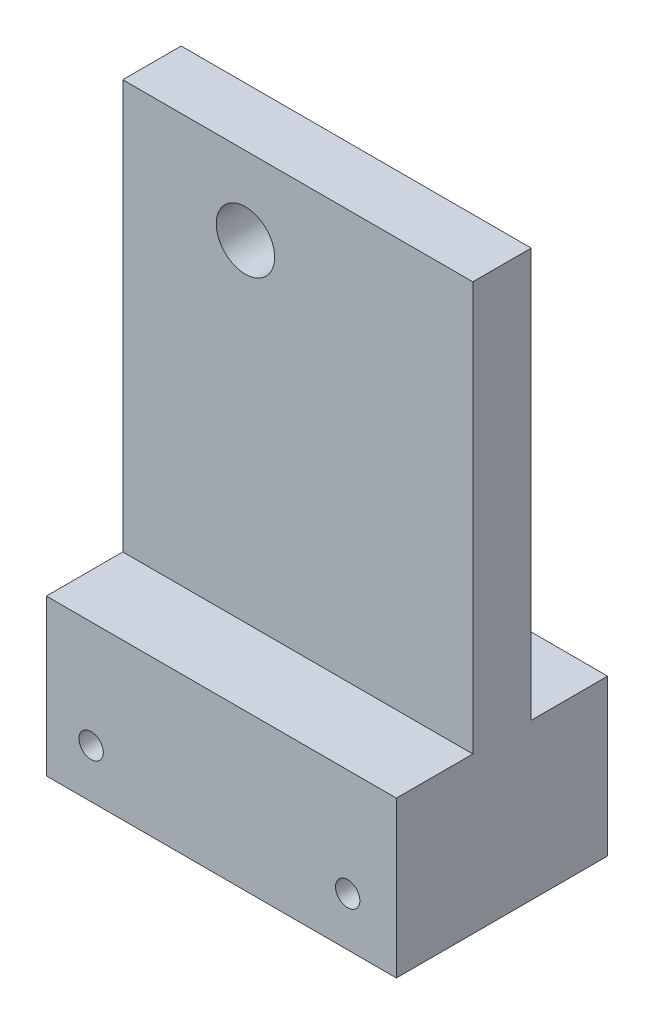
from build123d import *

# Parameters (mm, degrees)
SIDE_W                                      = 35.95
SIDE_H                                      = 10
AUFSATZ_LINEAR_AUSTRAGEN1_DEPTH             = 10.85
AUFSATZ_LINEAR_AUSTRAGEN1_DEPTH_BACK        = 10.85
SKIZZE5_R                                   = 1.25
SCHNITT_LINEAR_AUSTRAGEN1_DEPTH             = 11.85
SCHNITT_LINEAR_AUSTRAGEN1_DEPTH_BACK        = 11.85
TOPEXTENSION_W                              = 35.95
TOPEXTENSION_H                              = 48
TOPEXTENSION_R                              = 3
AUFSATZ_LINEAR_AUSTRAGEN2_DEPTH             = 3
AUFSATZ_LINEAR_AUSTRAGEN2_DEPTH_BACK        = 3
AUFSATZ_LINEAR_AUSTRAGEN3_REACH             = 12.85
SKIZZE8_W                                   = 35.95
SKIZZE8_H                                   = 6
AUFSATZ_LINEAR_AUSTRAGEN3_DIRECTION_2_REACH = 12.85


with BuildPart() as part:
    # Side → Aufsatz-Linear austragen1 (new body, two sides)
    with BuildSketch(Plane.XY) as aufsatz_linear_austragen1_sk:
        with Locations((5.375, 625)):
            Rectangle(SIDE_W, SIDE_H)
    extrude(amount=AUFSATZ_LINEAR_AUSTRAGEN1_DEPTH)
    extrude(aufsatz_linear_austragen1_sk.sketch, amount=-AUFSATZ_LINEAR_AUSTRAGEN1_DEPTH_BACK)

    # Skizze5 → Schnitt-Linear austragen1 (cut, two sides)
    with BuildSketch(Plane.XY) as schnitt_linear_austragen1_sk:
        with Locations((-8, 625)):
            Circle(SKIZZE5_R)
        with Locations((18.35, 625)):
            Circle(SKIZZE5_R)
    extrude(amount=SCHNITT_LINEAR_AUSTRAGEN1_DEPTH, mode=Mode.SUBTRACT)
    extrude(schnitt_linear_austragen1_sk.sketch, amount=-SCHNITT_LINEAR_AUSTRAGEN1_DEPTH_BACK, mode=Mode.SUBTRACT)

    # TopExtension → Aufsatz-Linear austragen2 (add, two sides)
    with BuildSketch(Plane.XY) as aufsatz_linear_austragen2_sk:
        with Locations((5.375, 654)):
            Rectangle(TOPEXTENSION_W, TOPEXTENSION_H)
        with Locations((0, 670)):
            Circle(TOPEXTENSION_R, mode=Mode.SUBTRACT)
    extrude(amount=AUFSATZ_LINEAR_AUSTRAGEN2_DEPTH)
    extrude(aufsatz_linear_austragen2_sk.sketch, amount=-AUFSATZ_LINEAR_AUSTRAGEN2_DEPTH_BACK)

    # Aufsatz-Linear austragen3: up to this face of the body (flat: up to its plane)
    aufsatz_linear_austragen3_end = Plane(part.part.faces().sort_by_distance((5.38061508, 625, 10.85))[0])
    # Skizze8 → Aufsatz-Linear austragen3 (add, up to the picked face)
    with BuildSketch(Plane.XY, mode=Mode.PRIVATE) as aufsatz_linear_austragen3_sk1:
        with Locations((5.375, 633)):
            Rectangle(SKIZZE8_W, SKIZZE8_H)
    aufsatz_linear_austragen3_tool1 = split(extrude(aufsatz_linear_austragen3_sk1.sketch, amount=AUFSATZ_LINEAR_AUSTRAGEN3_REACH, mode=Mode.PRIVATE), bisect_by=aufsatz_linear_austragen3_end, keep=Keep.BOTH, mode=Mode.PRIVATE)
    add(aufsatz_linear_austragen3_tool1.solids().sort_by_distance((5.375, 633, 0))[0])

    # Aufsatz-Linear austragen3 direction 2: up to this face of the body (flat: up to its plane)
    aufsatz_linear_austragen3_direction_2_end = Plane(part.part.faces().sort_by_distance((5.38061508, 625, -10.85))[0])
    # Skizze8 → Aufsatz-Linear austragen3 direction 2 (add, up to the picked face)
    with BuildSketch(Plane.XY, mode=Mode.PRIVATE) as aufsatz_linear_austragen3_direction_2_sk1:
        with Locations((5.375, 633)):
            Rectangle(SKIZZE8_W, SKIZZE8_H)
    aufsatz_linear_austragen3_direction_2_tool1 = split(extrude(aufsatz_linear_austragen3_direction_2_sk1.sketch, amount=-AUFSATZ_LINEAR_AUSTRAGEN3_DIRECTION_2_REACH, mode=Mode.PRIVATE), bisect_by=aufsatz_linear_austragen3_direction_2_end, keep=Keep.BOTH, mode=Mode.PRIVATE)
    add(aufsatz_linear_austragen3_direction_2_tool1.solids().sort_by_distance((5.375, 633, 0))[0])


solid = part.part
